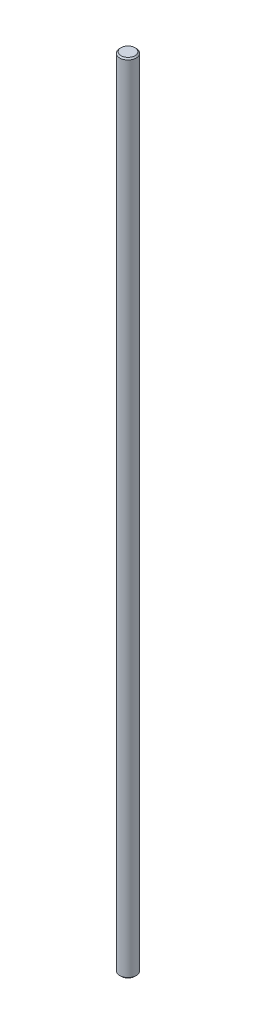
from build123d import *


with BuildPart() as part:
    # Sketch1 → Revolve1 (revolve)
    with BuildSketch(Plane(origin=(0, 0, 0), x_dir=(-1, 0, 0), z_dir=(0, 0, -1))):
        Polygon((-2.66319, 0), (0, 0), (0, 304.8), (-2.66319, 304.8), (-3.17119, 304.292), (-3.17119, 0.508), align=None)
    revolve(axis=Axis((0, 0, 0), (0, 1, 0)))


solid = part.part
